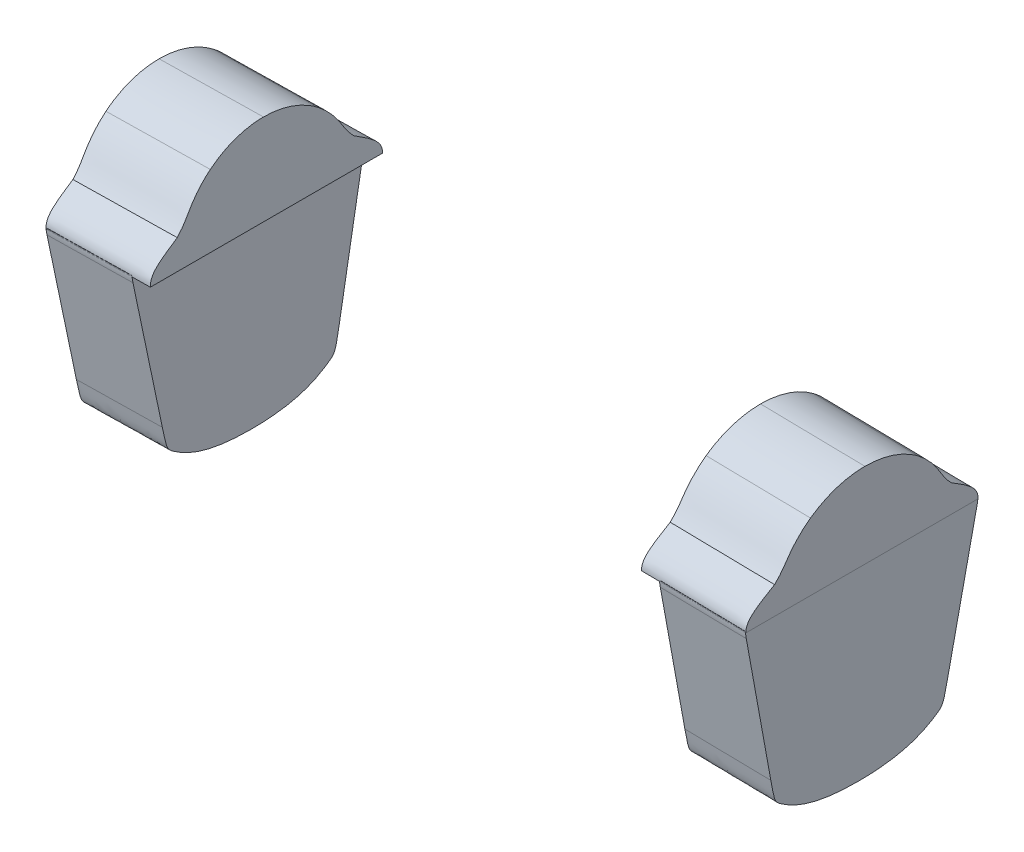
from build123d import *

# Parameters (mm, degrees)
BOSS_EXTRUDE1_START = 50
BOSS_EXTRUDE1_DEPTH = 70
BOSS_EXTRUDE2_DEPTH = 85


with BuildPart() as part:
    # Sketch13 → Boss-Extrude1 (new body)
    with BuildSketch(Plane(origin=(-330.938581291, -5.776554424, 0), x_dir=(0, 0, -1), z_dir=(0.9998476951563913, 0.01745240643728355, 0)).offset(BOSS_EXTRUDE1_START)):
        with BuildLine():
            Line((82.504968651, 100.854974304), (104.452952185, 212.763587252))
            add(Edge.make_bspline(
                [(104.452952185, 212.763587252), (104.764498054, 214.181600294), (104.976143339, 215.502076683), (105.095831682, 217.193489763), (105.111794857, 217.62180705), (105.111781315, 218.043266649)],
                knots=[0.000353847, 0.000353847, 0.000353847, 0.000353847, 0.125, 0.125, 0.168294021, 0.168294021, 0.168294021, 0.168294021], degree=3, weights=[1, 1, 1, 1, 1, 1]))
            Line((105.111781315, 218.043266649), (-84.033853266, 218.043266649))
            add(Edge.make_bspline(
                [(-84.033853266, 218.043266649), (-84.033866807, 217.62180705), (-84.017903632, 217.193489763), (-83.898215289, 215.502076683), (-83.686570004, 214.181600294), (-83.375024135, 212.763587252)],
                knots=[0.000353847, 0.000353847, 0.000353847, 0.000353847, 0.043647868, 0.043647868, 0.168294021, 0.168294021, 0.168294021, 0.168294021], degree=3, weights=[1, 1, 1, 1, 1, 1]))
            Line((-83.375024135, 212.763587252), (-61.427040601, 100.854974304))
            add(Edge.make_bspline(
                [(-61.427040601, 100.854974304), (-60.494790047, 96.10160523), (-59.806696514, 92.576509632), (-58.831152152, 88.589983566), (-58.516165741, 87.480729344), (-58.028983561, 86.075587392), (-57.864859581, 85.651850966), (-57.527194102, 84.87463305), (-57.35311836, 84.520356118), (-56.813561639, 83.546853759), (-56.423179112, 82.998912783), (-55.499344635, 81.961030232), (-54.954134222, 81.460285565), (-53.604433618, 80.398916906), (-52.801791648, 79.840644438), (-50.885825541, 78.583974383), (-49.776496201, 77.887687596), (-48.494126087, 77.076926385)],
                knots=[0, 0, 0, 0, 0.25, 0.25, 0.375, 0.375, 0.4375, 0.4375, 0.5, 0.5, 0.625, 0.625, 0.75, 0.75, 0.875, 0.875, 1, 1, 1, 1], degree=3, weights=[1, 1, 1, 1, 1, 1, 1, 1, 1, 1, 1, 1, 1, 1, 1, 1, 1, 1]))
            add(Edge.make_bspline(
                [(-48.494126087, 77.076926385), (-44.543093305, 74.578939183), (-40.318363864, 72.544738974), (-31.420829731, 69.20566255), (-26.752301669, 67.901703928), (-16.950534091, 65.872619322), (-11.818981459, 65.148967783), (-1.038541801, 64.197349426), (4.608967679, 63.970408152), (10.538964025, 63.970408152)],
                knots=[0, 0, 0, 0, 0.25, 0.25, 0.5, 0.5, 0.75, 0.75, 1, 1, 1, 1], degree=3, weights=[1, 1, 1, 1, 1, 1, 1, 1, 1, 1]))
            add(Edge.make_bspline(
                [(10.538964025, 63.970408152), (16.468960371, 63.970408152), (22.116469851, 64.197349426), (32.896909509, 65.148967783), (38.028462141, 65.872619322), (47.830229718, 67.901703928), (52.498757781, 69.20566255), (61.396291914, 72.544738974), (65.621021355, 74.578939183), (69.572054137, 77.076926385)],
                knots=[0, 0, 0, 0, 0.25, 0.25, 0.5, 0.5, 0.75, 0.75, 1, 1, 1, 1], degree=3, weights=[1, 1, 1, 1, 1, 1, 1, 1, 1, 1]))
            add(Edge.make_bspline(
                [(69.572054137, 77.076926385), (70.854424251, 77.887687596), (71.963753591, 78.583974383), (73.879719698, 79.840644438), (74.682361668, 80.398916906), (76.032062272, 81.460285565), (76.577272685, 81.961030232), (77.501107162, 82.998912783), (77.891489689, 83.546853759), (78.43104641, 84.520356118), (78.605122152, 84.87463305), (78.942787631, 85.651850966), (79.106911611, 86.075587392), (79.594093791, 87.480729344), (79.909080202, 88.589983566), (80.884624564, 92.576509632), (81.572718097, 96.10160523), (82.504968651, 100.854974304)],
                knots=[0, 0, 0, 0, 0.125, 0.125, 0.25, 0.25, 0.375, 0.375, 0.5, 0.5, 0.5625, 0.5625, 0.625, 0.625, 0.75, 0.75, 1, 1, 1, 1], degree=3, weights=[1, 1, 1, 1, 1, 1, 1, 1, 1, 1, 1, 1, 1, 1, 1, 1, 1, 1]))
        make_face()
    extrude(amount=BOSS_EXTRUDE1_DEPTH)


with BuildPart() as body_2:
    # Sketch14 → Boss-Extrude2 (new, along a direction that is not the sketch's normal)
    with BuildSketch(Plane(origin=(-277.087151572, -9.676096549, -4e-09), x_dir=(1.5547346451028226e-11, 5.429253016247e-13, -1.0), z_dir=(0.9993908270190958, 0.03489949670250105, 1.555682324741926e-11))):
        with BuildLine():
            Line((-84.02312349, 222.043116858), (105.101051477, 222.043116942))
            add(Edge.make_bspline(
                [(105.101051477, 222.043116942), (105.097325804, 222.293047893), (105.089811316, 222.797145544), (105.031269592, 223.558612238), (104.93157502, 224.331061774), (104.781530882, 225.114068797), (104.576373799, 225.907101154), (104.31032476, 226.709649583), (103.977523987, 227.521270024), (103.571732161, 228.341663052), (103.087699279, 229.17171607), (102.168395946, 230.533257575), (100.750647054, 232.177025122), (98.958411436, 233.857678136), (97.551533606, 235.033745954), (96.120574712, 236.160736228), (94.460092287, 237.391222075), (92.306961641, 238.893154628), (90.007540379, 240.426884672), (87.575910372, 241.997065912), (85.029205798, 243.605731349), (83.291005507, 244.685224487), (82.407558899, 245.233880794)],
                knots=[0, 0, 0, 0, 0.02213701, 0.04464919, 0.067605494, 0.091095652, 0.115221248, 0.140113262, 0.165931227, 0.19285997, 0.221121513, 0.250979323, 0.338288377, 0.412598456, 0.468467138, 0.500662074, 0.573936393, 0.651492419, 0.733182667, 0.818755679, 0.907881916, 1, 1, 1, 1], degree=3))
            add(Edge.make_bspline(
                [(82.407558899, 245.233880794), (80.417549382, 247.243429156), (78.739063844, 249.344273376), (77.157071832, 251.324343327), (75.524027068, 253.792440217), (74.91057153, 254.719584247), (74.034156299, 256.10415758), (73.912222563, 256.296790242), (73.299583543, 257.267735229), (72.85117774, 257.978394121), (72.563410027, 258.430120495), (71.739032549, 259.724195651), (71.066653076, 260.736627418), (70.254970794, 261.958813639), (69.513797564, 263.000091337), (66.335407941, 267.465425612), (62.503194987, 271.43001026), (58.68871458, 275.376249845), (54.322701875, 278.726937052)],
                knots=[0, 0, 0, 0.125, 0.125, 0.25, 0.25, 0.3125, 0.3125, 0.34375, 0.34375, 0.375, 0.375, 0.4375, 0.4375, 0.5, 0.5, 0.75, 0.75, 1, 1, 1], degree=2))
            add(Edge.make_bspline(
                [(54.322701875, 278.726937052), (49.645352491, 282.313502464), (44.446291859, 285.09138411), (39.268950288, 287.857661165), (33.71083578, 289.748463821), (28.096546015, 291.658376613), (22.24434246, 292.623376075), (16.431155423, 293.581941905), (10.538963962, 293.581940883)],
                knots=[0, 0, 0, 0.25, 0.25, 0.5, 0.5, 0.75, 0.75, 1, 1, 1], degree=2))
            add(Edge.make_bspline(
                [(10.538963962, 293.581940883), (4.632489641, 293.58194088), (-1.195479392, 292.61857541), (-6.980573736, 291.662297142), (-12.535598903, 289.781484343), (-18.135468052, 287.885488329), (-23.351828867, 285.1002087), (-28.559481552, 282.319578783), (-33.244780822, 278.726931435)],
                knots=[0, 0, 0, 0.25, 0.25, 0.5, 0.5, 0.75, 0.75, 1, 1, 1], degree=2))
            add(Edge.make_bspline(
                [(-33.244780822, 278.726931435), (-37.615751479, 275.37242508), (-41.434608165, 271.420335714), (-45.275304321, 267.445644939), (-48.459977102, 262.966195442), (-49.200313636, 261.924863932), (-50.012705082, 260.700552966), (-50.682250297, 259.691517787), (-51.508255498, 258.394358659), (-51.792237706, 257.948392809), (-52.243887917, 257.232539851), (-52.832165332, 256.300136598), (-52.978056753, 256.069716036), (-53.851342507, 254.690450607), (-54.46725564, 253.760476806), (-56.096044577, 251.301151035), (-57.677556743, 249.323729445), (-59.348609601, 247.234351905), (-61.329630932, 245.23388073)],
                knots=[0, 0, 0, 0.25, 0.25, 0.5, 0.5, 0.5625, 0.5625, 0.625, 0.625, 0.65625, 0.65625, 0.6875, 0.6875, 0.75, 0.75, 0.875, 0.875, 1, 1, 1], degree=2))
            add(Edge.make_bspline(
                [(-61.329630932, 245.23388073), (-63.505924199, 243.883244311), (-64.918269473, 242.9931114), (-66.873887417, 241.760580004), (-68.48073604, 240.712251527), (-70.427041898, 239.442456833), (-71.993903259, 238.355874312), (-73.912951945, 237.025057936), (-75.413157461, 235.864898512), (-77.260802787, 234.436052189), (-78.628503428, 233.144524544), (-80.332167648, 231.535744545), (-81.44575595, 229.988968308), (-82.089344287, 229.095022903), (-82.56383405, 228.186795359), (-83.064035723, 227.229352287), (-83.389529519, 226.227315254), (-84.018845169, 224.289958553), (-84.02312349, 222.043116858)],
                knots=[0, 0, 0, 0.125, 0.125, 0.25, 0.25, 0.375, 0.375, 0.5, 0.5, 0.625, 0.625, 0.75, 0.75, 0.8125, 0.8125, 0.875, 0.875, 1, 1, 1], degree=2))
        make_face()
    extrude(amount=BOSS_EXTRUDE2_DEPTH, dir=(0.9998476951564179, 0.017452406435759186, 7.779591801866449e-12))


with BuildPart() as body_3:
    # Mirror5: mirrored copy
    add(part.part.mirror(Plane(origin=(0, 0, 0), x_dir=(0, 0, 1), z_dir=(1, 0, 0))))


with BuildPart() as body_4:
    # Mirror5 2: mirrored copy
    add(body_2.part.mirror(Plane(origin=(0, 0, 0), x_dir=(0, 0, 1), z_dir=(1, 0, 0))))


solid = Compound([part.part, body_2.part, body_3.part, body_4.part])
